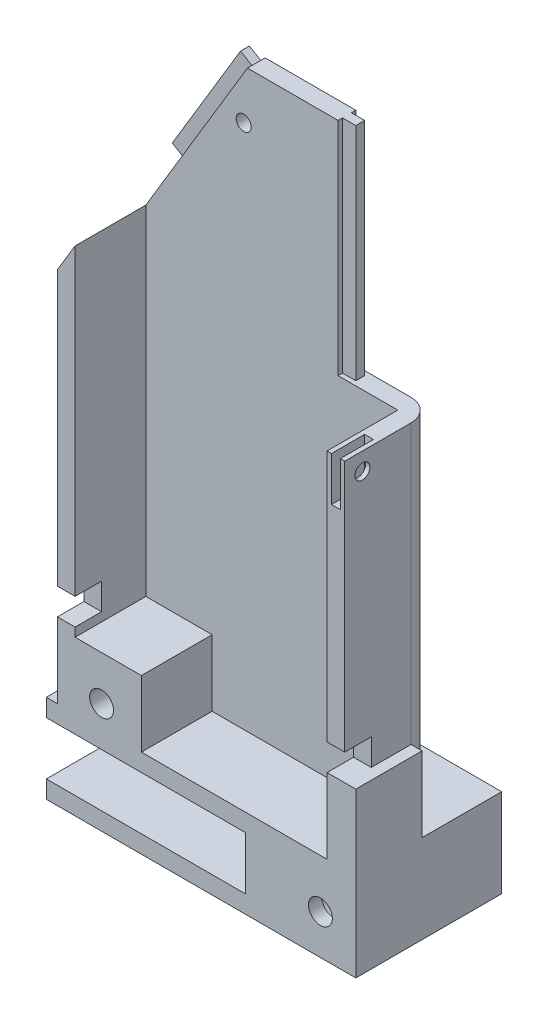
from build123d import *

# Parameters (mm, degrees)
SKETCH1_W                = 65
SKETCH1_H                = 40
BOSS_EXTRUDE1_DEPTH      = 130
SHELL1_T                 = -4
FILLET1_R                = 5
CUT_EXTRUDE1_DEPTH       = 21
CUT_EXTRUDE1_DEPTH_BACK  = 21
SKETCH3_W                = 17.5
SKETCH3_H                = 50
CUT_EXTRUDE2_DEPTH       = 21
CUT_EXTRUDE2_DEPTH_BACK  = 21
SKETCH5_W                = 2
SKETCH5_H                = 50
BOSS_EXTRUDE2_DEPTH      = 3
SKETCH6_W                = 2
SKETCH6_H                = 30
BOSS_EXTRUDE3_DEPTH      = 3
SKETCH8_W                = 70
SKETCH8_H                = 66
BOSS_EXTRUDE4_DEPTH      = 20
SKETCH10_W               = 60
SKETCH10_H               = 12
CUT_EXTRUDE4_DEPTH       = 45
SKETCH23_W               = 2
SKETCH23_H               = 15
CUT_EXTRUDE10_DEPTH      = 10
SKETCH27_W               = 70
SKETCH27_H               = 33
CUT_EXTRUDE12_DEPTH      = 132.543487266
CUT_EXTRUDE12_DEPTH_BACK = 21
SKETCH31_R               = 2.7
CUT_EXTRUDE15_DEPTH      = 1
CUT_EXTRUDE15_DEPTH_BACK = 34
SKETCH33_R               = 4.5
CUT_EXTRUDE16_DEPTH      = 30
SKETCH34_R               = 1.7
CUT_EXTRUDE17_DEPTH      = 132.543487266
CUT_EXTRUDE17_DEPTH_BACK = 21
SKETCH35_R               = 4
CUT_EXTRUDE18_DEPTH      = 2
SKETCH41_W               = 6
SKETCH41_H               = 6
CUT_EXTRUDE21_DEPTH      = 3.5
CUT_EXTRUDE21_DEPTH_BACK = 68.5
SKETCH42_W               = 15
SKETCH42_H               = 17
BOSS_EXTRUDE10_DEPTH     = 2.5
SKETCH43_R               = 1.7
CUT_EXTRUDE22_DEPTH      = 3.5
CUT_EXTRUDE22_DEPTH_BACK = 10
SKETCH45_W               = 4.6
SKETCH45_H               = 4
BOSS_EXTRUDE11_DEPTH     = 3
CUT_EXTRUDE23_DEPTH      = 5
FILLET2_R                = 1
SKETCH49_R               = 1.7
CUT_EXTRUDE24_DEPTH      = 16.153953894
CUT_EXTRUDE24_DEPTH_BACK = 21
SKETCH50_W               = 15
SKETCH50_H               = 15
BOSS_EXTRUDE12_DEPTH     = 16
SKETCH52_R               = 4.2
CUT_EXTRUDE25_DEPTH      = 15
SKETCH53_R               = 2.7
CUT_EXTRUDE26_DEPTH      = 31.153953894
CUT_EXTRUDE26_DEPTH_BACK = 6


with BuildPart() as part:
    # Sketch1 → Boss-Extrude1 (new body)
    with BuildSketch(Plane(origin=(0, 0, 0), x_dir=(1, 0, 0), z_dir=(0, 1, 0))):
        Rectangle(SKETCH1_W, SKETCH1_H)
    extrude(amount=BOSS_EXTRUDE1_DEPTH)

    # Shell1
    shell1_openings = [part.faces().sort_by_distance(p)[0] for p in [
        (0, 130, 0),
        (0, 0, 0),
    ]]
    offset(amount=SHELL1_T, openings=shell1_openings, kind=Kind.INTERSECTION)

    # Fillet1
    fillet1_edges = [part.edges().sort_by_distance(p)[0] for p in [
        (32.5, 65, 20),
        (-32.5, 65, 20),
        (-32.5, 65, -20),
        (32.5, 65, -20),
    ]]
    fillet(fillet1_edges, radius=FILLET1_R)

    # Sketch2 → Cut-Extrude1 (cut, two sides)
    with BuildSketch(Plane.XY) as cut_extrude1_sk:
        Polygon((-5.5, 130), (-32.5, 85), (-32.5, 130), align=None)
    extrude(amount=CUT_EXTRUDE1_DEPTH, mode=Mode.SUBTRACT)
    extrude(cut_extrude1_sk.sketch, amount=-CUT_EXTRUDE1_DEPTH_BACK, mode=Mode.SUBTRACT)

    # Sketch3 → Cut-Extrude2 (cut, two sides)
    with BuildSketch(Plane.XY) as cut_extrude2_sk:
        with Locations((23.75, 105)):
            Rectangle(SKETCH3_W, SKETCH3_H)
    extrude(amount=CUT_EXTRUDE2_DEPTH, mode=Mode.SUBTRACT)
    extrude(cut_extrude2_sk.sketch, amount=-CUT_EXTRUDE2_DEPTH_BACK, mode=Mode.SUBTRACT)

    # Sketch5 → Boss-Extrude2 (add)
    with BuildSketch(Plane(origin=(15, 0, 0), x_dir=(0, 0, -1), z_dir=(1, 0, 0))):
        with Locations((-18, 105)):
            Rectangle(SKETCH5_W, SKETCH5_H)
    boss_extrude2 = extrude(amount=BOSS_EXTRUDE2_DEPTH)

    # Mirror1: Boss-Extrude2 across plane
    add(boss_extrude2.mirror(Plane.XY))

    # Sketch6 → Boss-Extrude3 (add)
    with BuildSketch(Plane(origin=(-61.397058824, 36.838235294, 0), x_dir=(0, 0, 1), z_dir=(-0.857492926, 0.514495755, 0))):
        with Locations((-18, 93.644353688)):
            Rectangle(SKETCH6_W, SKETCH6_H)
    boss_extrude3 = extrude(amount=BOSS_EXTRUDE3_DEPTH)

    # Mirror2: Boss-Extrude3 across plane
    add(boss_extrude3.mirror(Plane.XY))

    # Sketch8 → Boss-Extrude4 (add)
    with BuildSketch(Plane(origin=(0, 0, 0), x_dir=(1, 0, 0), z_dir=(0, 1, 0))):
        Rectangle(SKETCH8_W, SKETCH8_H)
    extrude(amount=-BOSS_EXTRUDE4_DEPTH)

    # Sketch10 → Cut-Extrude4 (cut)
    with BuildSketch(Plane.ZY.offset(35)):
        with Locations((0, -10)):
            Rectangle(SKETCH10_W, SKETCH10_H)
    extrude(amount=-CUT_EXTRUDE4_DEPTH, mode=Mode.SUBTRACT)

    # Sketch23 → Cut-Extrude10 (cut)
    with BuildSketch(Plane(origin=(0, 80, 0), x_dir=(1, 0, 0), z_dir=(0, 1, 0))):
        with Locations((30.5, 0)):
            Rectangle(SKETCH23_W, SKETCH23_H)
    extrude(amount=-CUT_EXTRUDE10_DEPTH, mode=Mode.SUBTRACT)

    # Sketch27 → Cut-Extrude12 (cut, two sides)
    with BuildSketch(Plane(origin=(0, 0, 0), x_dir=(1, 0, 0), z_dir=(0, 1, 0))) as cut_extrude12_sk:
        with Locations((0, -16.5)):
            Rectangle(SKETCH27_W, SKETCH27_H)
    extrude(amount=CUT_EXTRUDE12_DEPTH, mode=Mode.SUBTRACT)
    extrude(cut_extrude12_sk.sketch, amount=-CUT_EXTRUDE12_DEPTH_BACK, mode=Mode.SUBTRACT)

    # Sketch31 → Cut-Extrude15 (cut, two sides)
    with BuildSketch(Plane.XY) as cut_extrude15_sk:
        with Locations((27, -11)):
            Circle(SKETCH31_R)
    extrude(amount=CUT_EXTRUDE15_DEPTH, mode=Mode.SUBTRACT)
    extrude(cut_extrude15_sk.sketch, amount=-CUT_EXTRUDE15_DEPTH_BACK, mode=Mode.SUBTRACT)

    # Sketch33 → Cut-Extrude16 (cut)
    with BuildSketch(Plane(origin=(0, 0, -33), x_dir=(-1, 0, 0), z_dir=(0, 0, -1))):
        with Locations((-27, -11)):
            Circle(SKETCH33_R)
    extrude(amount=-CUT_EXTRUDE16_DEPTH, mode=Mode.SUBTRACT)

    # Sketch34 → Cut-Extrude17 (cut, two sides)
    with BuildSketch(Plane(origin=(0, 0, 0), x_dir=(1, 0, 0), z_dir=(0, 1, 0))) as cut_extrude17_sk:
        with Locations((0, 27)):
            Circle(SKETCH34_R)
    extrude(amount=CUT_EXTRUDE17_DEPTH, mode=Mode.SUBTRACT)
    extrude(cut_extrude17_sk.sketch, amount=-CUT_EXTRUDE17_DEPTH_BACK, mode=Mode.SUBTRACT)

    # Sketch35 → Cut-Extrude18 (cut)
    with BuildSketch(Plane(origin=(0, -20, 0), x_dir=(-1, 0, 0), z_dir=(0, -1, 0))):
        with Locations((0, 27)):
            Circle(SKETCH35_R)
    extrude(amount=-CUT_EXTRUDE18_DEPTH, mode=Mode.SUBTRACT)

    # Sketch41 → Cut-Extrude21 (cut, two sides)
    with BuildSketch(Plane(origin=(32.5, 0, 0), x_dir=(0, 0, -1), z_dir=(1, 0, 0))) as cut_extrude21_sk:
        with Locations((3, 20)):
            Rectangle(SKETCH41_W, SKETCH41_H)
    extrude(amount=CUT_EXTRUDE21_DEPTH, mode=Mode.SUBTRACT)
    extrude(cut_extrude21_sk.sketch, amount=-CUT_EXTRUDE21_DEPTH_BACK, mode=Mode.SUBTRACT)

    # Sketch42 → Boss-Extrude10 (add)
    with BuildSketch(Plane(origin=(32.5, 0, 0), x_dir=(0, 0, -1), z_dir=(1, 0, 0))):
        with Locations((7.5, 8.5)):
            Rectangle(SKETCH42_W, SKETCH42_H)
    extrude(amount=BOSS_EXTRUDE10_DEPTH)

    # Sketch43 → Cut-Extrude22 (cut, two sides)
    with BuildSketch(Plane(origin=(32.5, 0, 0), x_dir=(0, 0, -1), z_dir=(1, 0, 0))) as cut_extrude22_sk:
        with Locations((4, 76)):
            Circle(SKETCH43_R)
    extrude(amount=CUT_EXTRUDE22_DEPTH, mode=Mode.SUBTRACT)
    extrude(cut_extrude22_sk.sketch, amount=-CUT_EXTRUDE22_DEPTH_BACK, mode=Mode.SUBTRACT)

    # Sketch45 → Boss-Extrude11 (add)
    with BuildSketch(Plane(origin=(0, 0, -33), x_dir=(-1, 0, 0), z_dir=(0, 0, -1))):
        with Locations((27.1, -18)):
            Rectangle(SKETCH45_W, SKETCH45_H)
    extrude(amount=BOSS_EXTRUDE11_DEPTH)

    # Sketch46 → Cut-Extrude23 (cut, through all)
    with BuildSketch(Plane(origin=(0, -16, 0), x_dir=(1, 0, 0), z_dir=(0, 1, 0))):
        Polygon((-29.4, 33), (-24.8, 36), (-29.4, 36), align=None)
    extrude(amount=-CUT_EXTRUDE23_DEPTH, mode=Mode.SUBTRACT)

    # Fillet2
    fillet2_edges = [part.edges().sort_by_distance(p)[0] for p in [
        (-24.8, -18, -36),
    ]]
    fillet(fillet2_edges, radius=FILLET2_R)

    # Sketch49 → Cut-Extrude24 (cut, two sides)
    with BuildSketch(Plane(origin=(0, 0, -20), x_dir=(-1, 0, 0), z_dir=(0, 0, -1))) as cut_extrude24_sk:
        with Locations((6.357492926, 118.852591966)):
            Circle(SKETCH49_R)
    extrude(amount=CUT_EXTRUDE24_DEPTH, mode=Mode.SUBTRACT)
    extrude(cut_extrude24_sk.sketch, amount=-CUT_EXTRUDE24_DEPTH_BACK, mode=Mode.SUBTRACT)

    # Sketch50 → Boss-Extrude12 (add)
    with BuildSketch(Plane.XY.offset(-16)):
        with Locations((-21, 7.5)):
            Rectangle(SKETCH50_W, SKETCH50_H)
    extrude(amount=BOSS_EXTRUDE12_DEPTH)

    # Sketch52 → Cut-Extrude25 (cut)
    with BuildSketch(Plane(origin=(0, 0, -20), x_dir=(-1, 0, 0), z_dir=(0, 0, -1))):
        with Locations((22.5, 5)):
            Circle(SKETCH52_R)
    extrude(amount=-CUT_EXTRUDE25_DEPTH, mode=Mode.SUBTRACT)

    # Sketch53 → Cut-Extrude26 (cut, two sides)
    with BuildSketch(Plane(origin=(0, 0, -5), x_dir=(-1, 0, 0), z_dir=(0, 0, -1))) as cut_extrude26_sk:
        with Locations((22.5, 5)):
            Circle(SKETCH53_R)
    extrude(amount=CUT_EXTRUDE26_DEPTH, mode=Mode.SUBTRACT)
    extrude(cut_extrude26_sk.sketch, amount=-CUT_EXTRUDE26_DEPTH_BACK, mode=Mode.SUBTRACT)


solid = part.part
